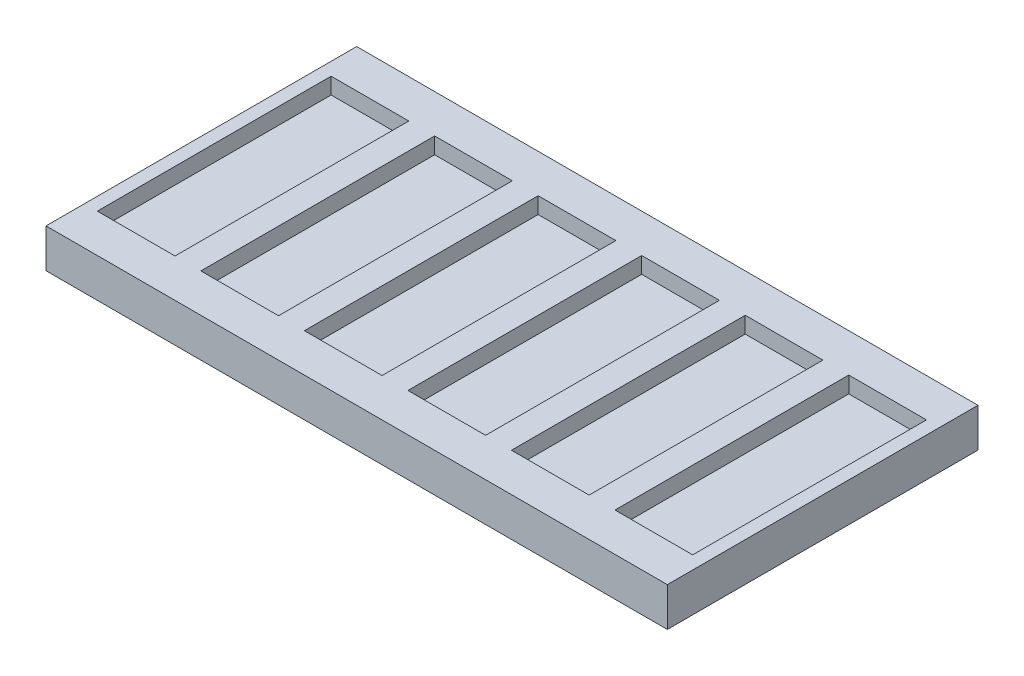
from build123d import *

# Parameters (mm, degrees)
SKETCH_1_W             = 80
SKETCH_1_H             = 40
EXTRUDE_1_DEPTH        = 5
SKETCH_2_W             = 10
SKETCH_2_H             = 30.1
CUT_EXTRUDE_1_DEPTH    = 2.1
PATTERN_LINEAR_1_COUNT = 6
PATTERN_LINEAR_1_PITCH = 13.33
EXTRUDE_2_DEPTH        = 80
CHAMFER_1_SIZE         = 6.1


with BuildPart() as part:
    # Эскиз1 → Бобышка-Вытянуть1 (new body)
    with BuildSketch(Plane(origin=(0, 0, 0), x_dir=(1, 0, 0), z_dir=(0, 1, 0))):
        Rectangle(SKETCH_1_W, SKETCH_1_H)
    extrude(amount=EXTRUDE_1_DEPTH)

    # Эскиз2 → Вырез-Вытянуть1 (cut)
    with BuildSketch(Plane(origin=(0, 5, 0), x_dir=(1, 0, 0), z_dir=(0, 1, 0))):
        with Locations((-33.34, 0)):
            Rectangle(SKETCH_2_W, SKETCH_2_H)
    cut_extrude_1 = extrude(amount=-CUT_EXTRUDE_1_DEPTH, mode=Mode.SUBTRACT)

    # Линейный массив1: Вырез-Вытянуть1 ×6
    with Locations(*[(i * PATTERN_LINEAR_1_PITCH, 0, 0) for i in range(1, PATTERN_LINEAR_1_COUNT)]):
        add(cut_extrude_1, mode=Mode.SUBTRACT)

    # Эскиз3 → Бобышка-Вытянуть2 (add)
    with BuildSketch(Plane.ZY.offset(40)):
        Polygon((-13.07, 0), (-13.07, -2), (-15.45, -2), (-15.45, -3.44), (-12.79, -6.1), (-7.21, -6.1), (-4.55, -3.44), (-4.55, -2), (-7.02, -2), (-7.02, 0), align=None)
        Polygon((7.02, 0), (13.07, 0), (13.07, -2), (15.45, -2), (15.45, -3.44), (12.79, -6.1), (7.21, -6.1), (4.55, -3.44), (4.55, -2), (7.02, -2), align=None)
    extrude(amount=-EXTRUDE_2_DEPTH)

    # Фаска1
    chamfer_1_edges = [part.edges().sort_by_distance(p)[0] for p in [
        (40, -6.1, 10),
        (-40, -6.1, 10),
        (40, -6.1, -10),
        (-40, -6.1, -10),
    ]]
    chamfer(chamfer_1_edges, length=CHAMFER_1_SIZE)


solid = part.part
